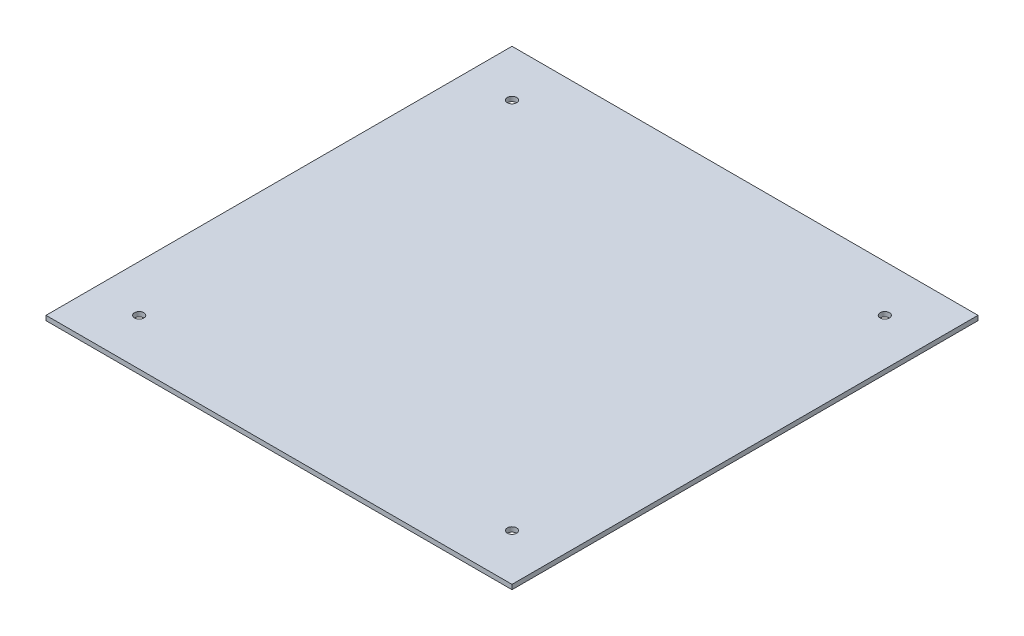
from build123d import *

# Parameters (mm, degrees)
SKETCH2_W           = 500
SKETCH2_H           = 500
BOSS_EXTRUDE1_DEPTH = 5
SKETCH3_R           = 5
CUT_EXTRUDE1_DEPTH  = 10


with BuildPart() as part:
    # Sketch2 → Boss-Extrude1 (new body)
    with BuildSketch(Plane(origin=(0, 0, 0), x_dir=(1, 0, 0), z_dir=(0, 1, 0))):
        Rectangle(SKETCH2_W, SKETCH2_H)
    extrude(amount=BOSS_EXTRUDE1_DEPTH)

    # Sketch3 → Cut-Extrude1 (cut)
    with BuildSketch(Plane(origin=(0, 5, 0), x_dir=(1, 0, 0), z_dir=(0, 1, 0))):
        with Locations((-200, 200)):
            Circle(SKETCH3_R)
        with Locations((-200, -200)):
            Circle(SKETCH3_R)
        with Locations((200, 200)):
            Circle(SKETCH3_R)
        with Locations((200, -200)):
            Circle(SKETCH3_R)
    extrude(amount=-CUT_EXTRUDE1_DEPTH, mode=Mode.SUBTRACT)


solid = part.part
